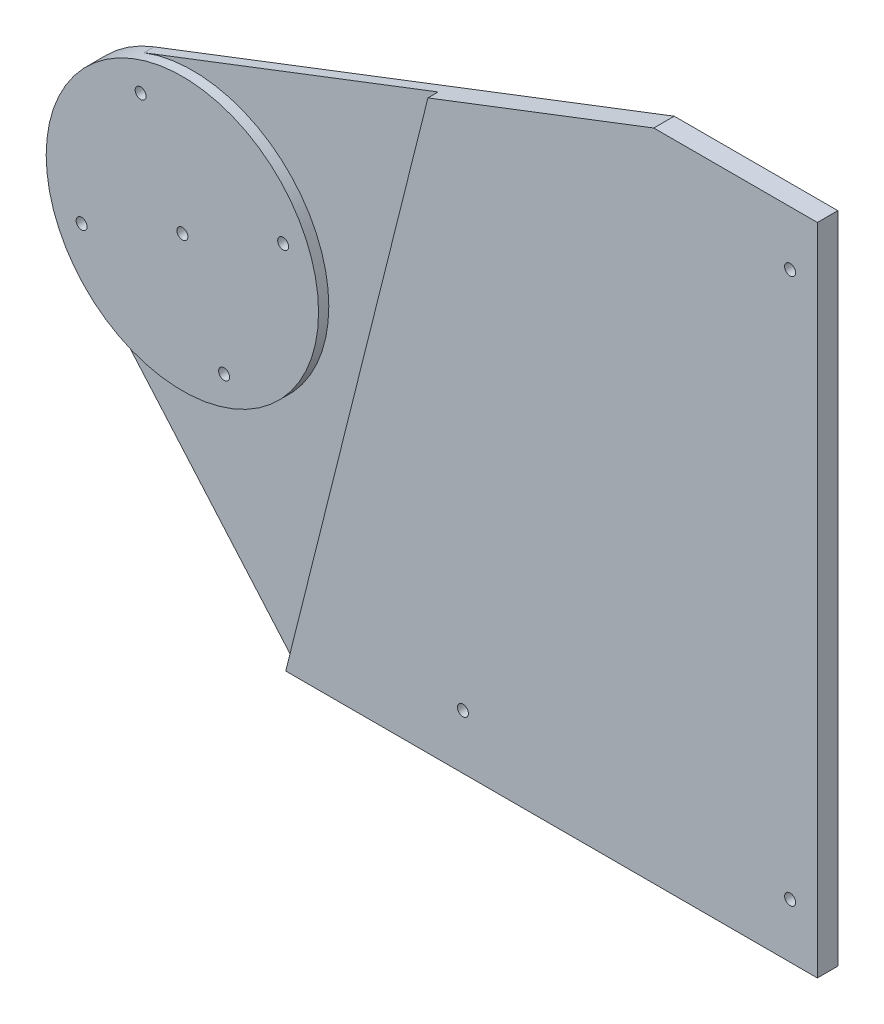
from build123d import *
from build123d.topology import SkipClean

# Parameters (mm, degrees)
BOSS_EXTRUDE1_DEPTH     = 9.525
CUT_EXTRUDE4_DEPTH      = 4.7752
F_1_4_20_TAPPED_HOLE1_D = 5.1054


with BuildPart() as part:
    # Sketch1 → Boss-Extrude1 (new body)
    with BuildSketch(Plane.XY):
        with BuildLine():
            ThreePointArc((-22.767324083, 59.210121486), (-61.545192335, 15.374616506), (-47.937560329, -41.547320514))
            Line((-47.937560329, -41.547320514), (48.13808, -152.4))
            Line((48.13808, -152.4), (295.78808, -152.4))
            Line((295.78808, -152.4), (295.78808, 152.4))
            Line((295.78808, 152.4), (219.58808, 152.4))
            Line((219.58808, 152.4), (-22.767324083, 59.210121486))
        make_face()
    extrude(amount=-BOSS_EXTRUDE1_DEPTH)

    # Sketch1_5 → Cut-Extrude4 (cut)
    with SkipClean():  # keep this step's faces unmerged: merging them makes the solid invalid here
        with BuildSketch(Plane.XY):
            with BuildLine():
                Line((114.391061614, 111.949912244), (-22.767324083, 59.210121486))
                ThreePointArc((-22.767324083, 59.210121486), (35.915944774, 52.289907661), (63.4365, 0))
                ThreePointArc((63.4365, 0), (22.172037417, -59.435597827), (-47.937560329, -41.547320514))
                Line((-47.937560329, -41.547320514), (48.13808, -152.4))
                Line((48.13808, -152.4), (114.391061614, 111.949912244))
            make_face()
        extrude(amount=-CUT_EXTRUDE4_DEPTH, mode=Mode.SUBTRACT)

    # 1_4-20 Tapped Hole1 (through all)
    with Locations(Plane.XY):
        with Locations((283.08808, 127), (283.08808, -127), (130.68808, -127), (46.933080252, 19.440318364), (19.440318364, -46.933080252), (-46.933080252, -19.440318364), (-19.440318364, 46.933080252), (0, 0)):
            Hole(F_1_4_20_TAPPED_HOLE1_D / 2)


solid = part.part
